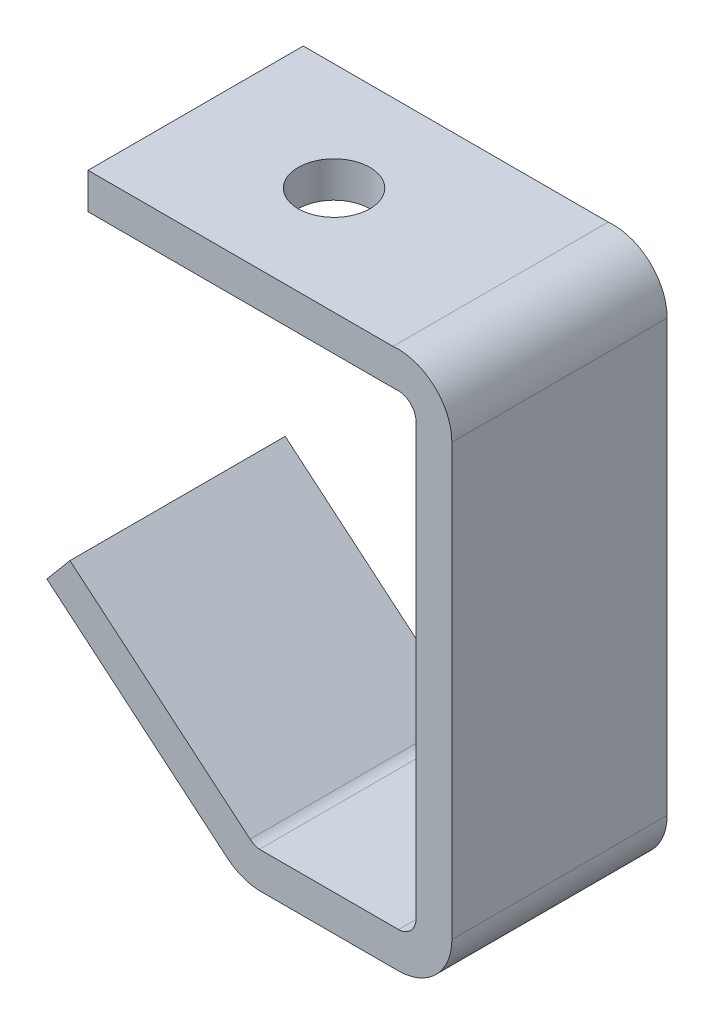
from build123d import *

# Parameters (mm, degrees)
BOSS_EXTRUDE1_DEPTH = 38.1
SKETCH2_R           = 6.35
CUT_EXTRUDE1_DEPTH  = 38.1


with BuildPart() as part:
    # Sketch1 → Boss-Extrude1 (new body)
    with BuildSketch(Plane.XY):
        with BuildLine():
            Line((0, 0), (53.98, 0))
            ThreePointArc((53.98, 0), (61.287211447, -2.441393787), (64.401363743, -9.488222735))
            Line((64.401363743, -9.488222735), (64.401363743, -85.721240556))
            ThreePointArc((64.401363743, -85.721240556), (61.664237719, -92.40538322), (55.025128035, -95.25))
            Line((55.025128035, -95.25), (30.071323434, -95.25))
            ThreePointArc((30.071323434, -95.25), (27.161692752, -94.580250085), (24.602099349, -93.043045718))
            Line((24.602099349, -93.043045718), (-7.280670374, -66.290225402))
            Line((-7.280670374, -66.290225402), (-3.198969052, -61.425843189))
            Line((-3.198969052, -61.425843189), (28.68380067, -88.178663504))
            ThreePointArc((28.68380067, -88.178663504), (29.463882201, -88.660646082), (30.349062467, -88.9))
            Line((30.349062467, -88.9), (54.96018039, -88.9))
            ThreePointArc((54.96018039, -88.9), (57.151148485, -87.938216318), (58.051363743, -85.721240556))
            Line((58.051363743, -85.721240556), (58.051363743, -9.488222735))
            ThreePointArc((58.051363743, -9.488222735), (56.930321756, -7.064776449), (54.357595252, -6.35))
            Line((54.357595252, -6.35), (0, -6.35))
            Line((0, -6.35), (0, 0))
        make_face()
    extrude(amount=BOSS_EXTRUDE1_DEPTH)

    # Sketch2 → Cut-Extrude1 (cut)
    with BuildSketch(Plane(origin=(0, 0, 0), x_dir=(1, 0, 0), z_dir=(0, 1, 0))):
        with Locations((24.5, -19.05)):
            Circle(SKETCH2_R)
    extrude(amount=-CUT_EXTRUDE1_DEPTH, mode=Mode.SUBTRACT)


solid = part.part
